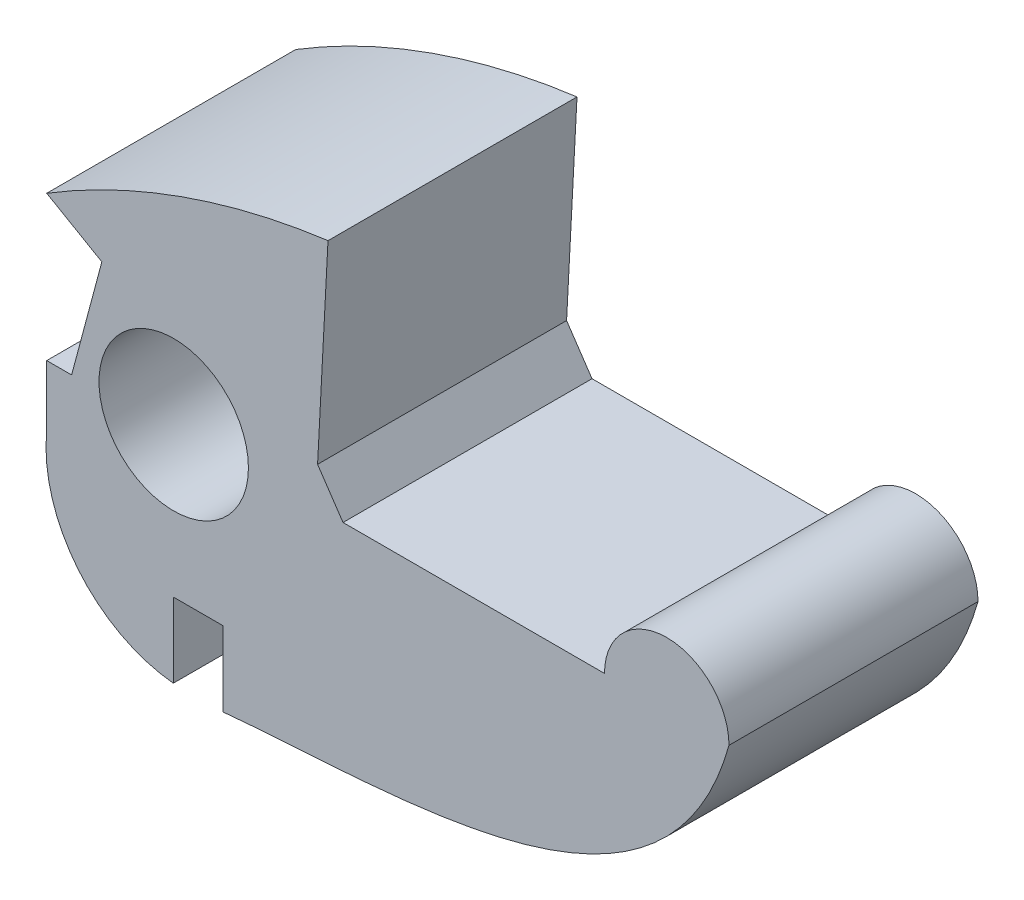
from build123d import *

# Parameters (mm, degrees)
SKETCH1_R           = 3
BOSS_EXTRUDE1_DEPTH = 10


with BuildPart() as part:
    # Sketch1 → Boss-Extrude1 (new body)
    with BuildSketch(Plane.XY):
        with BuildLine():
            Line((10.5, 0), (0, 0))
            Line((0, 0), (-1.022323327, 1.510963722))
            Line((-1.022323327, 1.510963722), (-0.603635677, 9.5))
            ThreePointArc((-0.603635677, 9.5), (-6.462853921, 8.095985117), (-11.9, 5.5))
            Line((-11.9, 5.5), (-9.686017962, 4.221756874))
            Line((-9.686017962, 4.221756874), (-10.9, -0.318754948))
            Line((-10.9, -0.318754948), (-11.9, -0.318754948))
            Line((-11.9, -0.318754948), (-11.9, -2.769258551))
            ThreePointArc((-11.9, -2.769258551), (-10.648945281, -6.93734622), (-6.81703295, -9))
            Line((-6.81703295, -9), (-6.81703295, -6))
            Line((-6.81703295, -6), (-4.81703295, -6))
            Line((-4.81703295, -6), (-4.81703295, -9))
            add(Edge.make_bspline(
                [(-4.81703295, -9), (2.115225064, -8.331257602), (12.97604793, -9.010983468), (15.5, 0)],
                knots=[0.063235072, 0.063235072, 0.063235072, 0.063235072, 1.063235072, 1.063235072, 1.063235072, 1.063235072], degree=3))
            ThreePointArc((15.5, 0), (13, 2.5), (10.5, 0))
        make_face()
        with Locations((-6.8, 0)):
            Circle(SKETCH1_R, mode=Mode.SUBTRACT)
    extrude(amount=BOSS_EXTRUDE1_DEPTH)


solid = part.part
